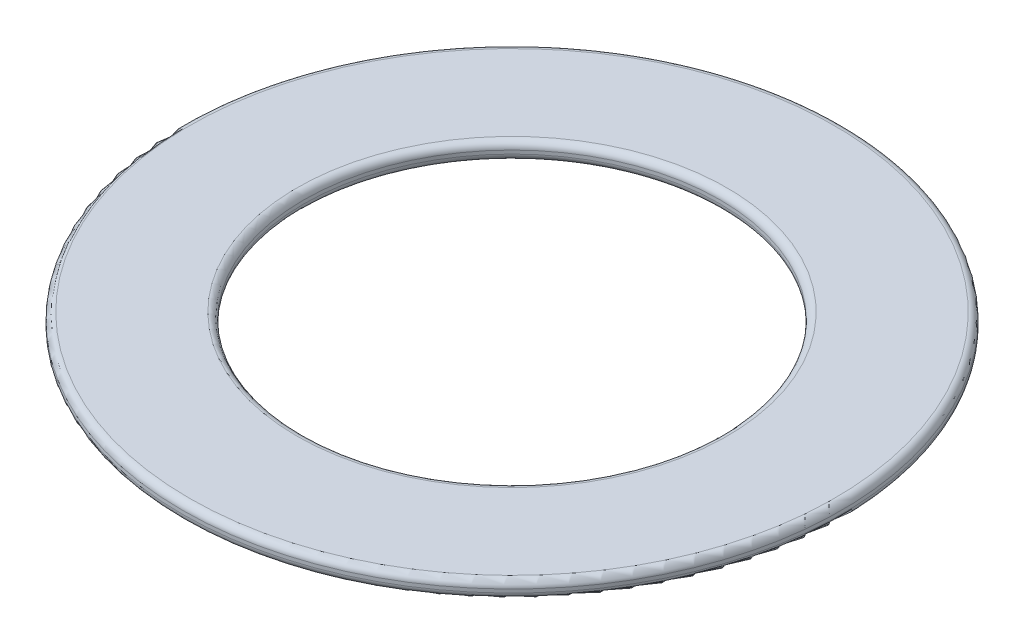
from build123d import *

# Parameters (mm, degrees)
SKETCH1_R           = 9.5
SKETCH1_R_2         = 6
BOSS_EXTRUDE1_DEPTH = 0.5
FILLET1_R           = 0.2


with BuildPart() as part:
    # Sketch1 → Boss-Extrude1 (new body)
    with BuildSketch(Plane(origin=(0, 0, 0), x_dir=(1, 0, 0), z_dir=(0, 1, 0))):
        Circle(SKETCH1_R)
        Circle(SKETCH1_R_2, mode=Mode.SUBTRACT)
    extrude(amount=BOSS_EXTRUDE1_DEPTH)

    # Fillet1
    fillet1_edges = [part.edges().sort_by_distance(p)[0] for p in [
        (-9.5, 0, 0),
        (-9.5, 0.5, 0),
        (-6, 0, 0),
        (-6, 0.5, 0),
    ]]
    fillet(fillet1_edges, radius=FILLET1_R)


solid = part.part
